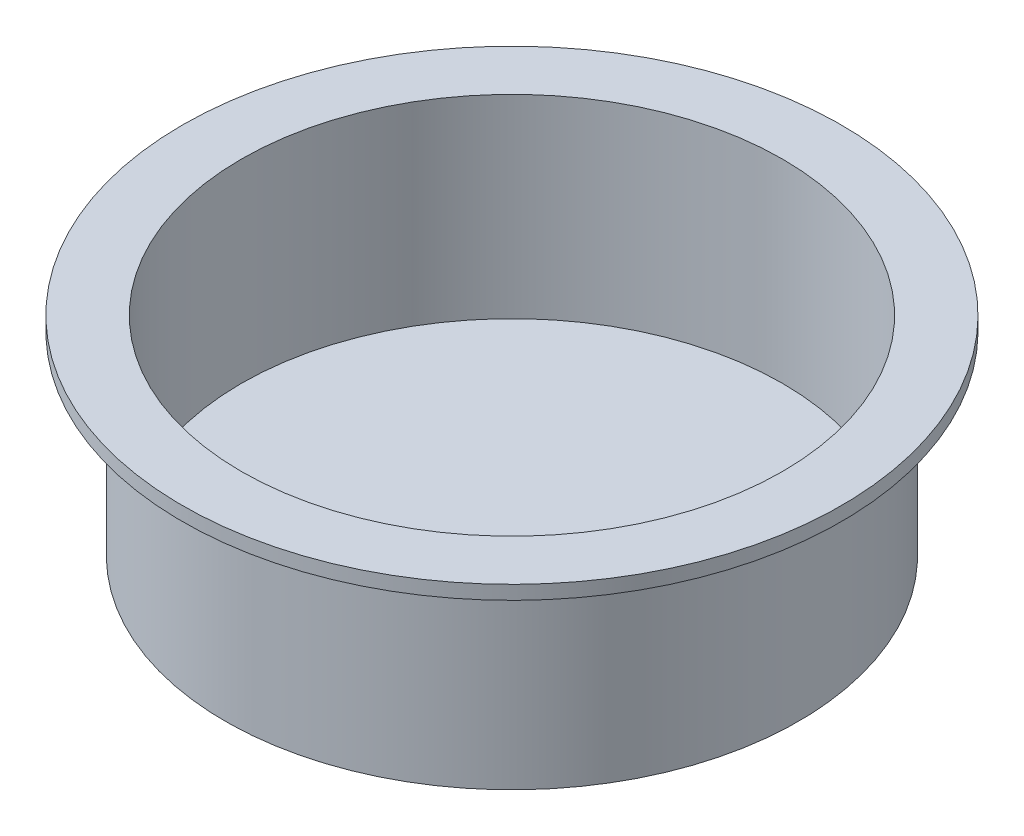
from build123d import *

# Parameters (mm, degrees)
SKETCH4_R          = 24.765
CUT_EXTRUDE1_DEPTH = 17.78


with BuildPart() as part:
    # Sketch3 → Revolve1 (revolve)
    with BuildSketch(Plane.XY):
        Polygon((0, 0), (26.2509, 0), (26.2509, 17.78), (30.1625, 17.78), (30.1625, 19.05), (0, 19.05), align=None)
    revolve(axis=Axis((0, 19.05, 0), (0, -1, 0)))

    # Sketch4 → Cut-Extrude1 (cut)
    with BuildSketch(Plane(origin=(0, 19.05, 0), x_dir=(1, 0, 0), z_dir=(0, 1, 0))):
        Circle(SKETCH4_R)
    extrude(amount=-CUT_EXTRUDE1_DEPTH, mode=Mode.SUBTRACT)


solid = part.part
